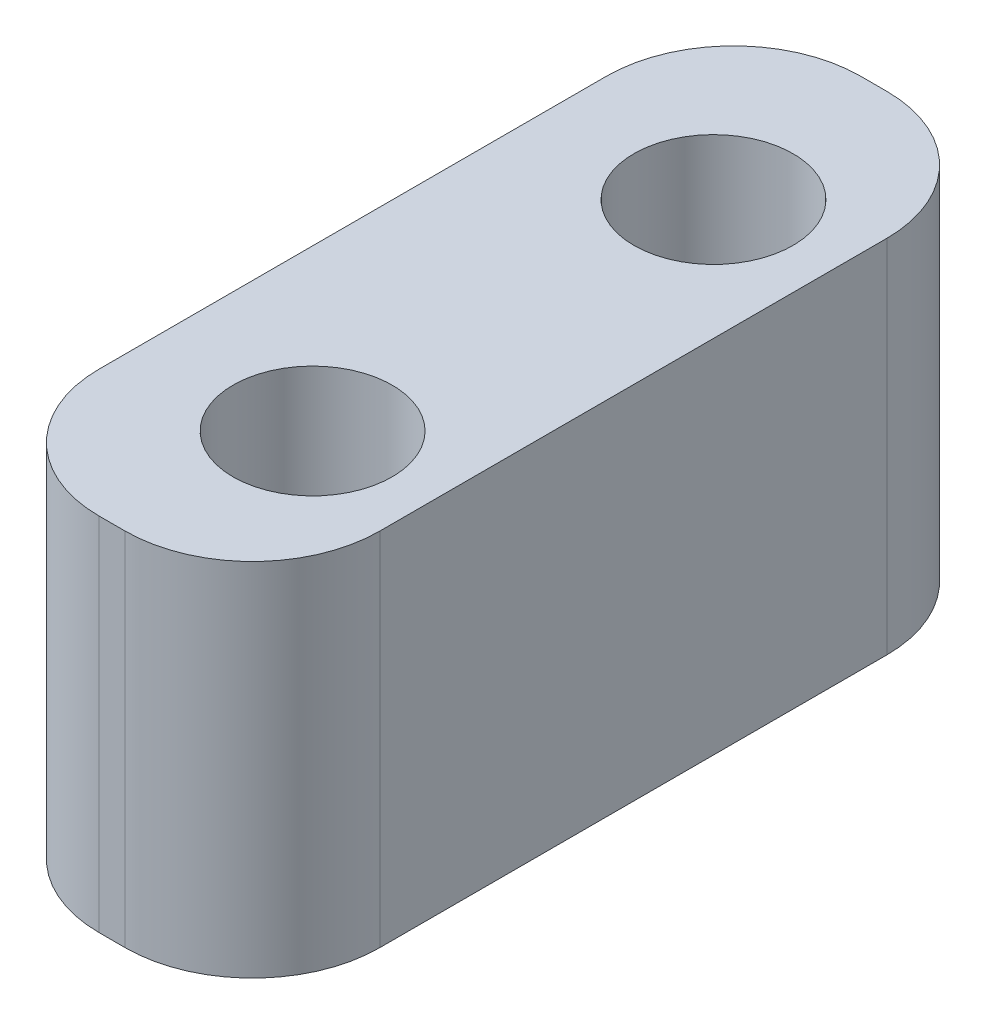
from build123d import *

# Parameters (mm, degrees)
SKETCH1_W           = 7
SKETCH1_H           = 9
BOSS_EXTRUDE1_DEPTH = 19
SKETCH2_R           = 1.984375
CUT_EXTRUDE1_DEPTH  = 9
FILLET1_R           = 3.175


with BuildPart() as part:
    # Sketch1 → Boss-Extrude1 (new body)
    with BuildSketch(Plane.XY):
        with Locations((3.5, 4.5)):
            Rectangle(SKETCH1_W, SKETCH1_H)
    extrude(amount=BOSS_EXTRUDE1_DEPTH)

    # Sketch2 → Cut-Extrude1 (cut)
    with BuildSketch(Plane(origin=(0, 9, 0), x_dir=(1, 0, 0), z_dir=(0, 1, 0))):
        with Locations((4, -4.5)):
            Circle(SKETCH2_R)
        with Locations((4, -14.5)):
            Circle(SKETCH2_R)
    extrude(amount=-CUT_EXTRUDE1_DEPTH, mode=Mode.SUBTRACT)

    # Fillet1
    fillet1_edges = [part.edges().sort_by_distance(p)[0] for p in [
        (7, 4.5, 19),
        (0, 4.5, 19),
        (7, 4.5, 0),
        (0, 4.5, 0),
    ]]
    fillet(fillet1_edges, radius=FILLET1_R)


solid = part.part
